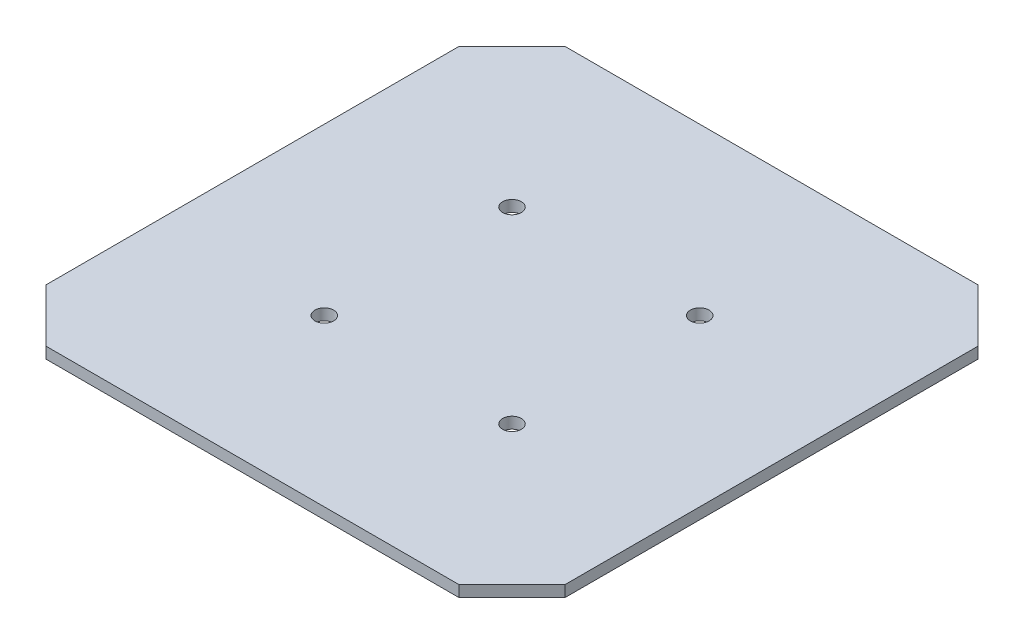
from build123d import *

# Parameters (mm, degrees)
SKETCH1_R           = 2.5
BOSS_EXTRUDE2_DEPTH = 3


with BuildPart() as part:
    # Sketch1 → Boss-Extrude2 (new body)
    with BuildSketch(Plane(origin=(0, 0, 0), x_dir=(1, 0, 0), z_dir=(0, 1, 0))):
        Polygon((-69.142135624, 55), (-55, 69.142135624), (55, 69.142135624), (69.142135624, 55), (69.142135624, -55), (55, -69.142135624), (-55, -69.142135624), (-69.142135624, -55), align=None)
        with Locations((-25, 25)):
            Circle(SKETCH1_R, mode=Mode.SUBTRACT)
        with Locations((25, 25)):
            Circle(SKETCH1_R, mode=Mode.SUBTRACT)
        with Locations((25, -25)):
            Circle(SKETCH1_R, mode=Mode.SUBTRACT)
        with Locations((-25, -25)):
            Circle(SKETCH1_R, mode=Mode.SUBTRACT)
    extrude(amount=BOSS_EXTRUDE2_DEPTH)


solid = part.part
